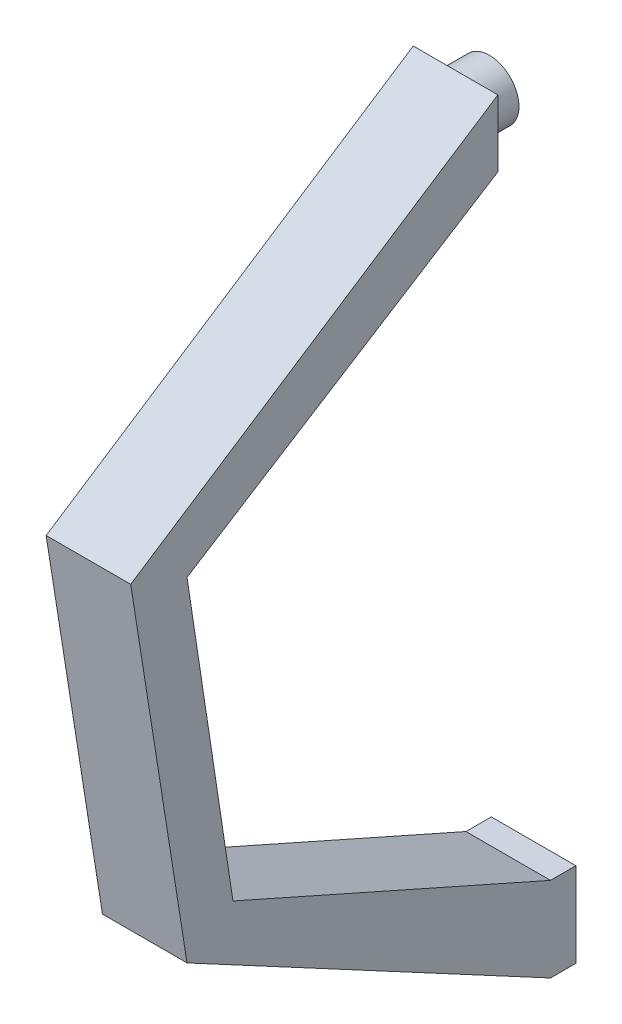
from build123d import *

# Parameters (mm, degrees)
SKETCH1_W           = 100
SKETCH1_H           = 100
BOSS_EXTRUDE1_DEPTH = 30
BOSS_EXTRUDE2_DEPTH = 100
SKETCH4_R           = 35
BOSS_EXTRUDE3_DEPTH = 40


with BuildPart() as part:
    # Sketch1 → Boss-Extrude1 (new body)
    with BuildSketch(Plane.XY):
        with Locations((50, 50)):
            Rectangle(SKETCH1_W, SKETCH1_H)
    extrude(amount=BOSS_EXTRUDE1_DEPTH)

    # Sketch2 → Boss-Extrude2 (add)
    with BuildSketch(Plane(origin=(0, 0, 0), x_dir=(0, 0, -1), z_dir=(1, 0, 0))):
        Polygon((-30, 100), (-405.545697471, 266.651744151), (-459.843779827, 625.256045564), (-92.290312011, 856.669682909), (-92.290312011, 935.622570944), (-526.435767621, 651.422136489), (-459.843779827, 230.355875203), (-30, 0), align=None)
    extrude(amount=BOSS_EXTRUDE2_DEPTH)

    # Sketch4 → Boss-Extrude3 (add)
    with BuildSketch(Plane(origin=(0, 0, 92.290312011), x_dir=(-1, 0, 0), z_dir=(0, 0, -1))):
        with Locations((-50, 896.146126927)):
            Circle(SKETCH4_R)
    extrude(amount=BOSS_EXTRUDE3_DEPTH)


solid = part.part
